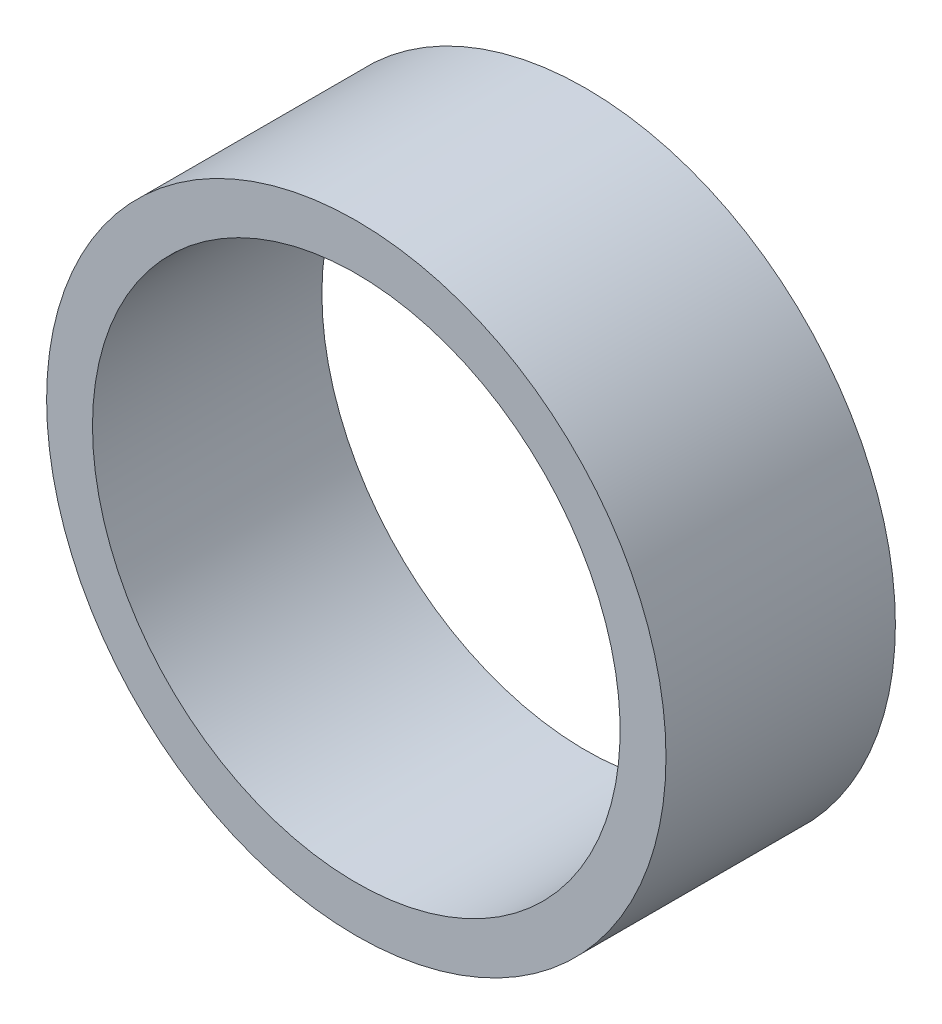
from build123d import *

# Parameters (mm, degrees)
SKETCH1_R           = 1.35
BOSS_EXTRUDE1_DEPTH = 1
SKETCH2_R           = 1.15
CUT_EXTRUDE1_DEPTH  = 2


with BuildPart() as part:
    # Sketch1 → Boss-Extrude1 (new body)
    with BuildSketch(Plane.XY):
        Circle(SKETCH1_R)
    extrude(amount=-BOSS_EXTRUDE1_DEPTH)

    # Sketch2 → Cut-Extrude1 (cut, through all)
    with BuildSketch(Plane(origin=(0, 0, -1), x_dir=(-1, 0, 0), z_dir=(0, 0, -1))):
        Circle(SKETCH2_R)
    extrude(amount=-CUT_EXTRUDE1_DEPTH, mode=Mode.SUBTRACT)


solid = part.part
